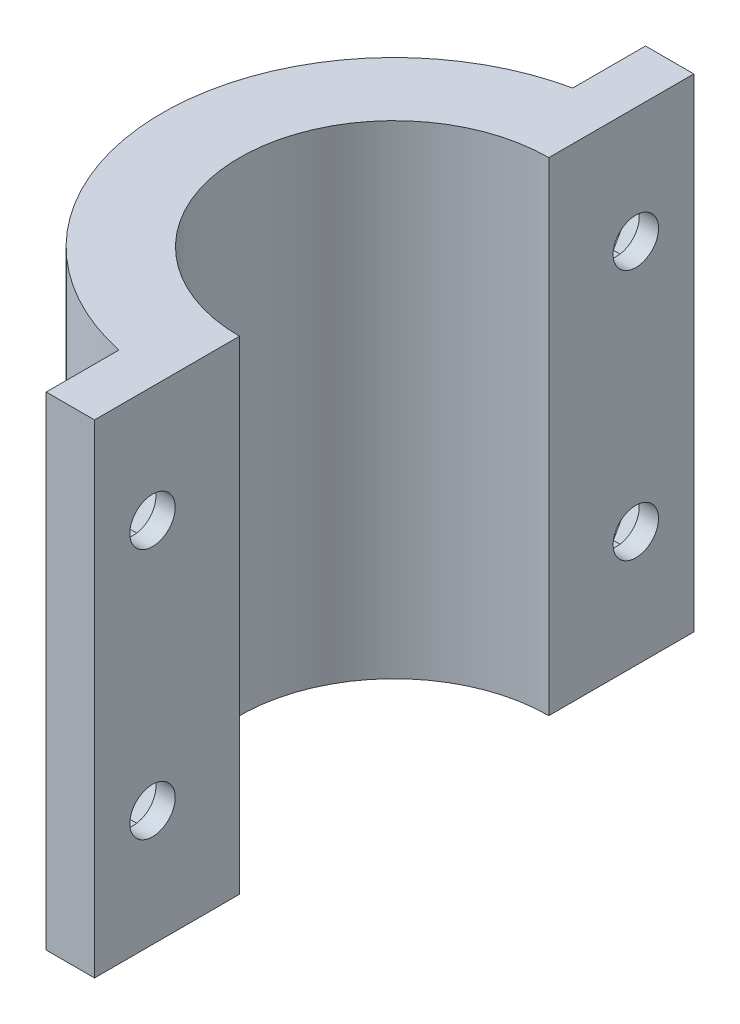
from build123d import *

# Parameters (mm, degrees)
BOSS_EXTRUDE1_DEPTH = 50
CUT_EXTRUDE1_DEPTH  = 50
SKETCH2_7_R         = 2.35
CUT_EXTRUDE5_DEPTH  = 10
SKETCH2_10_R        = 2.35
CUT_EXTRUDE8_DEPTH  = 3


with BuildPart() as part:
    # Sketch1 → Boss-Extrude1 (new body)
    with BuildSketch(Plane(origin=(0, 0, 0), x_dir=(1, 0, 0), z_dir=(0, 1, 0))):
        with BuildLine():
            Line((0, -16), (0, -31))
            Line((0, -31), (-5, -31))
            Line((-5, -31), (-5, -23.473389189))
            ThreePointArc((-5, -23.473389189), (-24, 0), (-5, 23.473389189))
            Line((-5, 23.473389189), (-5, 31))
            Line((-5, 31), (0, 31))
            Line((0, 31), (0, 16))
            ThreePointArc((0, 16), (-16, 0), (0, -16))
        make_face()
    extrude(amount=BOSS_EXTRUDE1_DEPTH)

    # Sketch2 → Cut-Extrude1 (cut)
    with BuildSketch(Plane.ZY.offset(5)):
        Polygon((-22.329755005, 33.375), (-19.65951001, 38), (-22.329755005, 42.625), (-27.670244995, 42.625), (-30.34048999, 38), (-27.670244995, 33.375), align=None)
        Polygon((-22.329755005, 7.375), (-19.65951001, 12), (-22.329755005, 16.625), (-27.670244995, 16.625), (-30.34048999, 12), (-27.670244995, 7.375), align=None)
        Polygon((27.670244995, 7.375), (22.329755005, 7.375), (19.65951001, 12), (22.329755005, 16.625), (27.670244995, 16.625), (30.34048999, 12), align=None)
        Polygon((27.670244995, 42.625), (30.34048999, 38), (27.670244995, 33.375), (22.329755005, 33.375), (19.65951001, 38), (22.329755005, 42.625), align=None)
    extrude(amount=CUT_EXTRUDE1_DEPTH, mode=Mode.SUBTRACT)

    # Sketch2_7 → Cut-Extrude5 (cut)
    with BuildSketch(Plane.ZY.offset(5)):
        with Locations((-25, 38)):
            Circle(SKETCH2_7_R)
        with Locations((-25, 12)):
            Circle(SKETCH2_7_R)
        with Locations((25, 12)):
            Circle(SKETCH2_7_R)
        with Locations((25, 38)):
            Circle(SKETCH2_7_R)
    extrude(amount=-CUT_EXTRUDE5_DEPTH, mode=Mode.SUBTRACT)

    # Sketch2_10 → Cut-Extrude8 (cut)
    # profile 1 of 4: a face of its own
    with BuildSketch(Plane.ZY.offset(5)):
        Polygon((-22.329755005, 33.375), (-19.65951001, 38), (-22.329755005, 42.625), (-27.670244995, 42.625), (-30.34048999, 38), (-27.670244995, 33.375), align=None)
        with Locations((-25, 38)):
            Circle(SKETCH2_10_R, mode=Mode.SUBTRACT)
    # profile 2 of 4: a face of its own
    with BuildSketch(Plane.ZY.offset(5)):
        Polygon((-22.329755005, 7.375), (-19.65951001, 12), (-22.329755005, 16.625), (-27.670244995, 16.625), (-30.34048999, 12), (-27.670244995, 7.375), align=None)
        with Locations((-25, 12)):
            Circle(SKETCH2_10_R, mode=Mode.SUBTRACT)
    # profile 3 of 4: a face of its own
    with BuildSketch(Plane.ZY.offset(5)):
        Polygon((27.670244995, 7.375), (22.329755005, 7.375), (19.65951001, 12), (22.329755005, 16.625), (27.670244995, 16.625), (30.34048999, 12), align=None)
        with Locations((25, 12)):
            Circle(SKETCH2_10_R, mode=Mode.SUBTRACT)
    # profile 4 of 4: a face of its own
    with BuildSketch(Plane.ZY.offset(5)):
        Polygon((27.670244995, 42.625), (30.34048999, 38), (27.670244995, 33.375), (22.329755005, 33.375), (19.65951001, 38), (22.329755005, 42.625), align=None)
        with Locations((25, 38)):
            Circle(SKETCH2_10_R, mode=Mode.SUBTRACT)
    extrude(amount=-CUT_EXTRUDE8_DEPTH, mode=Mode.SUBTRACT)


solid = part.part
